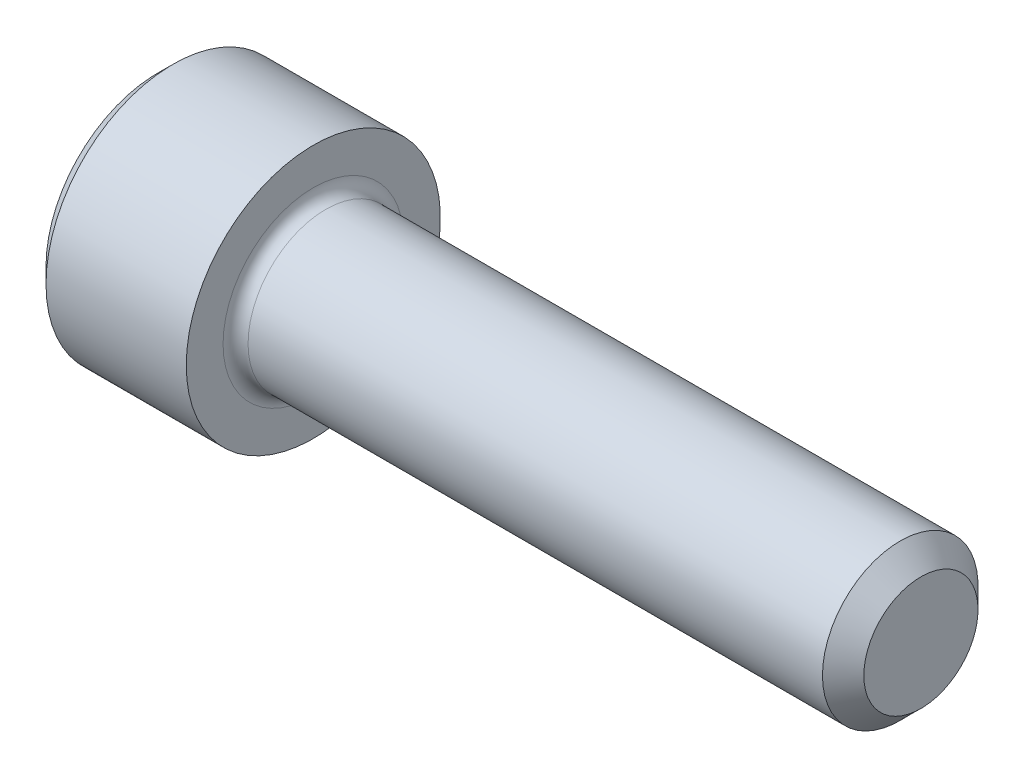
from build123d import *

# Parameters (mm, degrees)
FILLET1_R   = 0.2286
HEX_2_DEPTH = 1.2954


with BuildPart() as part:
    # BodySke → Base-Revolve (revolve)
    with BuildSketch(Plane.XY):
        Polygon((0, 0), (0, 2.0447), (0.2794, 2.3241), (2.8448, 2.3241), (2.8448, 1.4224), (13.57884, 1.4224), (13.9573, 1.04394), (13.9573, 0), align=None)
    revolve(axis=Axis((-31.75, 0, 0), (1, 0, 0)))

    # Fillet1
    fillet1_edges = [part.edges().sort_by_distance(p)[0] for p in [
        (2.8448, -1.4224, 0),
    ]]
    fillet(fillet1_edges, radius=FILLET1_R)

    # Sketch2 → Hex-PreBroach (revolve, cut)
    with BuildSketch(Plane.XY):
        Polygon((0, 1.1938), (1.2954, 1.1938), (1.984640751, 0), (0, 0), align=None)
    revolve(axis=Axis((0, 0, 0), (1, 0, 0)), mode=Mode.SUBTRACT)

    # Sketch3 → Hex 2 (cut)
    with BuildSketch(Plane(origin=(0, 0, 0), x_dir=(0, 0.5, 0.866025404), z_dir=(-1, 0, 0))):
        Polygon((0.689240751, 1.1938), (-0.689240751, 1.1938), (-1.378481503, 0), (-0.689240751, -1.1938), (0.689240751, -1.1938), (1.378481503, 0), align=None)
    extrude(amount=-HEX_2_DEPTH, mode=Mode.SUBTRACT)


solid = part.part
